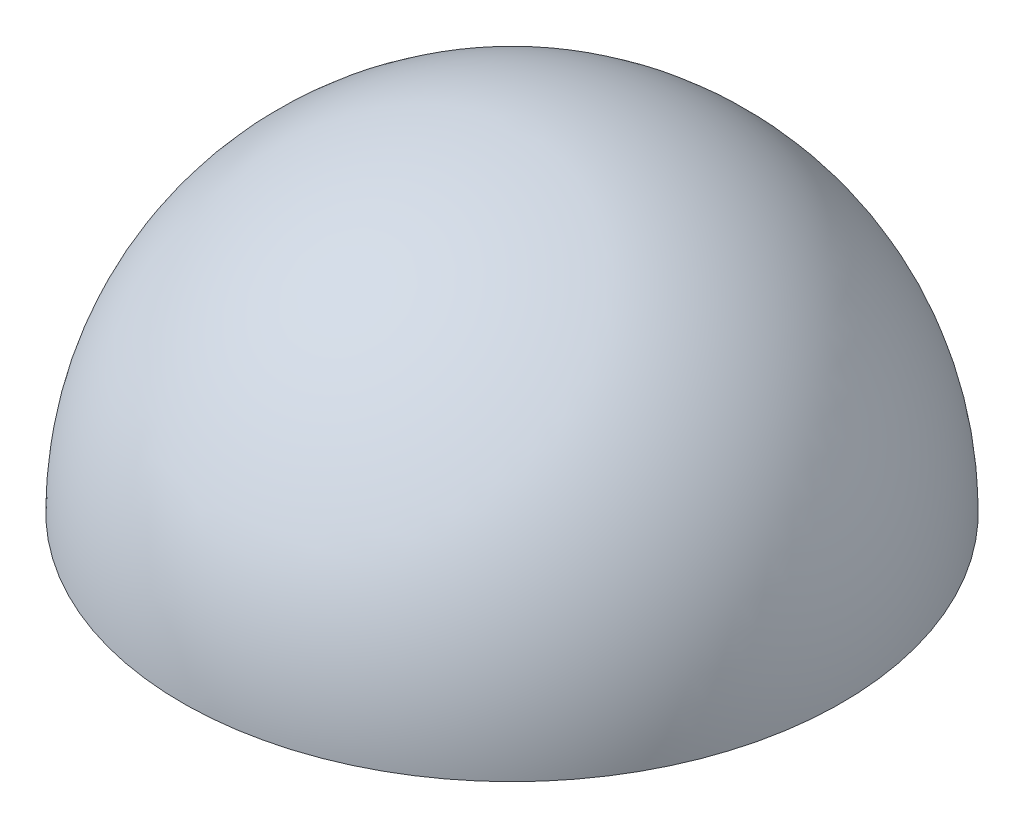
from build123d import *

# Parameters (mm, degrees)
REVOLVE1_ANGLE      = 180
SKETCH4_R           = 50
BOSS_EXTRUDE1_DEPTH = 7
SKETCH5_R           = 34.5
BOSS_EXTRUDE2_DEPTH = 12
SKETCH6_R           = 39
BOSS_EXTRUDE4_DEPTH = 4
SKETCH7_R           = 30
CUT_EXTRUDE1_DEPTH  = 24
CUT_EXTRUDE2_DEPTH  = 10


with BuildPart() as part:
    # Sketch1 → Revolve1 (revolve)
    with BuildSketch(Plane(origin=(0, 0, 0), x_dir=(1, 0, 0), z_dir=(0, 1, 0))):
        with BuildLine():
            Line((1.491717845, 54.979766986), (-1.491717845, -54.979766986))
            ThreePointArc((-1.491717845, -54.979766986), (54.979766986, -1.491717845), (1.491717845, 54.979766986))
        make_face()
    revolve(axis=Axis((1.491717845, 0, -54.979766986), (-0.027122143, 0, 0.999632127)), revolution_arc=REVOLVE1_ANGLE)

    # Sketch2 → Cut-Revolve1 (revolve, cut)
    with BuildSketch(Plane.XZ):
        with BuildLine():
            Line((49.980692072, 1.389395568), (-49.980692072, -1.389395568))
            ThreePointArc((-49.980692072, -1.389395568), (-1.389395568, 49.980692072), (49.980692072, 1.389395568))
        make_face()
    revolve(axis=Axis((49.980692072, 0, 1.389395568), (-0.999613841, 0, -0.027787911)), mode=Mode.SUBTRACT)

    # Sketch4 → Boss-Extrude1 (add)
    with BuildSketch(Plane.XZ):
        Circle(SKETCH4_R)
    extrude(amount=-BOSS_EXTRUDE1_DEPTH)

    # Sketch5 → Boss-Extrude2 (add)
    with BuildSketch(Plane.XZ):
        Circle(SKETCH5_R)
    extrude(amount=BOSS_EXTRUDE2_DEPTH)

    # Sketch6 → Boss-Extrude4 (add)
    with BuildSketch(Plane.XZ.offset(12)):
        Circle(SKETCH6_R)
    extrude(amount=-BOSS_EXTRUDE4_DEPTH)

    # Sketch7 → Cut-Extrude1 (cut)
    with BuildSketch(Plane.XZ.offset(12)):
        Circle(SKETCH7_R)
    extrude(amount=-CUT_EXTRUDE1_DEPTH, mode=Mode.SUBTRACT)

    # Sketch8 → Cut-Extrude2 (cut)
    with BuildSketch(Plane.XZ.offset(12)):
        with BuildLine():
            ThreePointArc((37.671107225, 10.093942759), (19.5, 33.774990748), (-10.093942759, 37.671107225))
            Line((-10.093942759, 37.671107225), (-9.058666579, 33.80740392))
            ThreePointArc((-9.058666579, 33.80740392), (17.5, 30.310889132), (33.80740392, 9.058666579))
            Line((33.80740392, 9.058666579), (37.671107225, 10.093942759))
        make_face()
        with BuildLine():
            ThreePointArc((-10.093942759, -37.671107225), (19.5, -33.774990748), (37.671107225, -10.093942759))
            Line((37.671107225, -10.093942759), (33.80740392, -9.058666579))
            ThreePointArc((33.80740392, -9.058666579), (17.5, -30.310889132), (-9.058666579, -33.80740392))
            Line((-9.058666579, -33.80740392), (-10.093942759, -37.671107225))
        make_face()
        with BuildLine():
            Line((-24.748737342, 24.748737342), (-27.577164466, 27.577164466))
            ThreePointArc((-27.577164466, 27.577164466), (-39, 0), (-27.577164466, -27.577164466))
            Line((-27.577164466, -27.577164466), (-24.748737342, -24.748737342))
            ThreePointArc((-24.748737342, -24.748737342), (-35, 0), (-24.748737342, 24.748737342))
        make_face()
    extrude(amount=-CUT_EXTRUDE2_DEPTH, mode=Mode.SUBTRACT)


solid = part.part
